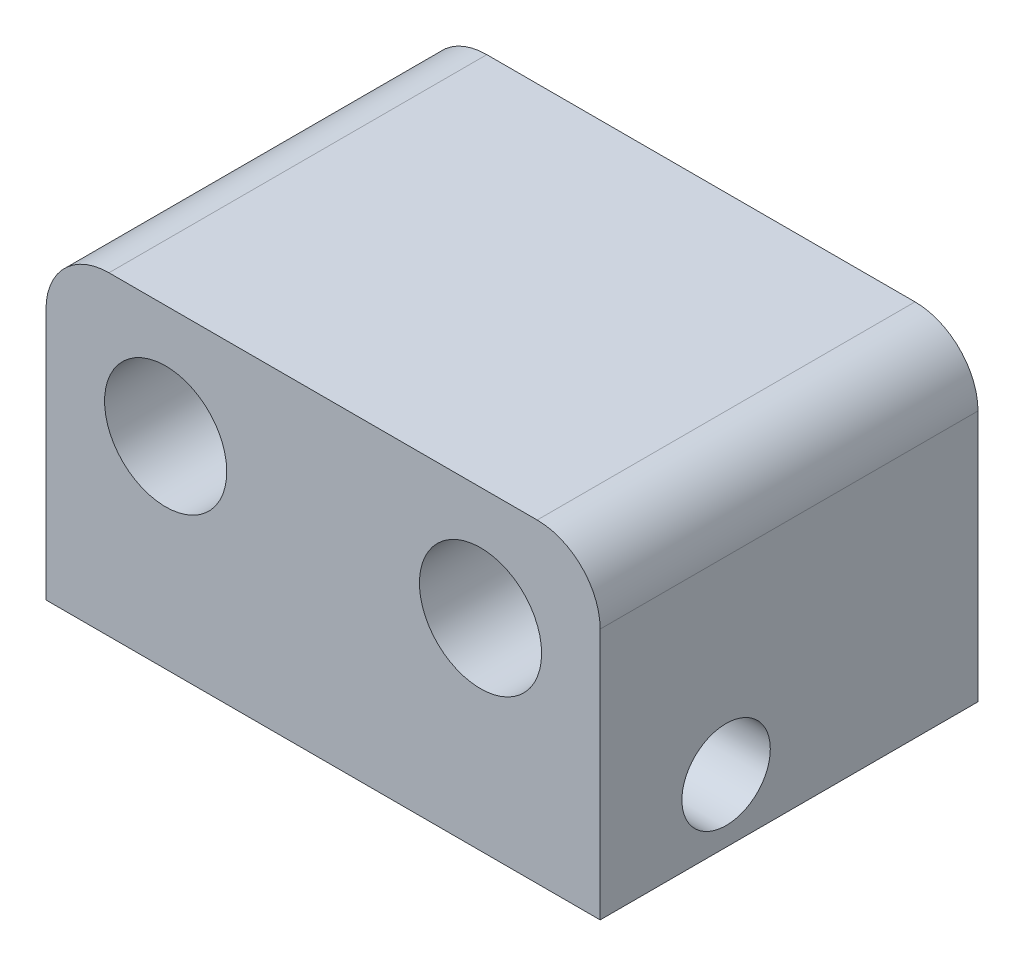
from build123d import *

# Parameters (mm, degrees)
SKETCH2_W           = 22
SKETCH2_H           = 12.5
SKETCH2_R           = 2.425
BOSS_EXTRUDE1_DEPTH = 15
SKETCH3_R           = 1.755
CUT_EXTRUDE1_DEPTH  = 30
FILLET1_R           = 2.5


with BuildPart() as part:
    # Sketch2 → Boss-Extrude1 (new body)
    with BuildSketch(Plane.XY):
        with Locations((0, 18.75)):
            Rectangle(SKETCH2_W, SKETCH2_H)
        with Locations((-6.25, 20.5)):
            Circle(SKETCH2_R, mode=Mode.SUBTRACT)
        with Locations((6.25, 20.5)):
            Circle(SKETCH2_R, mode=Mode.SUBTRACT)
    extrude(amount=BOSS_EXTRUDE1_DEPTH)

    # Sketch3 → Cut-Extrude1 (cut)
    with BuildSketch(Plane(origin=(11, 0, 0), x_dir=(0, 0, -1), z_dir=(1, 0, 0))):
        with Locations((-10, 15)):
            Circle(SKETCH3_R)
    extrude(amount=-CUT_EXTRUDE1_DEPTH, mode=Mode.SUBTRACT)

    # Fillet1
    fillet1_edges = [part.edges().sort_by_distance(p)[0] for p in [
        (-11, 25, 7.5),
        (11, 25, 7.5),
    ]]
    fillet(fillet1_edges, radius=FILLET1_R)


solid = part.part
